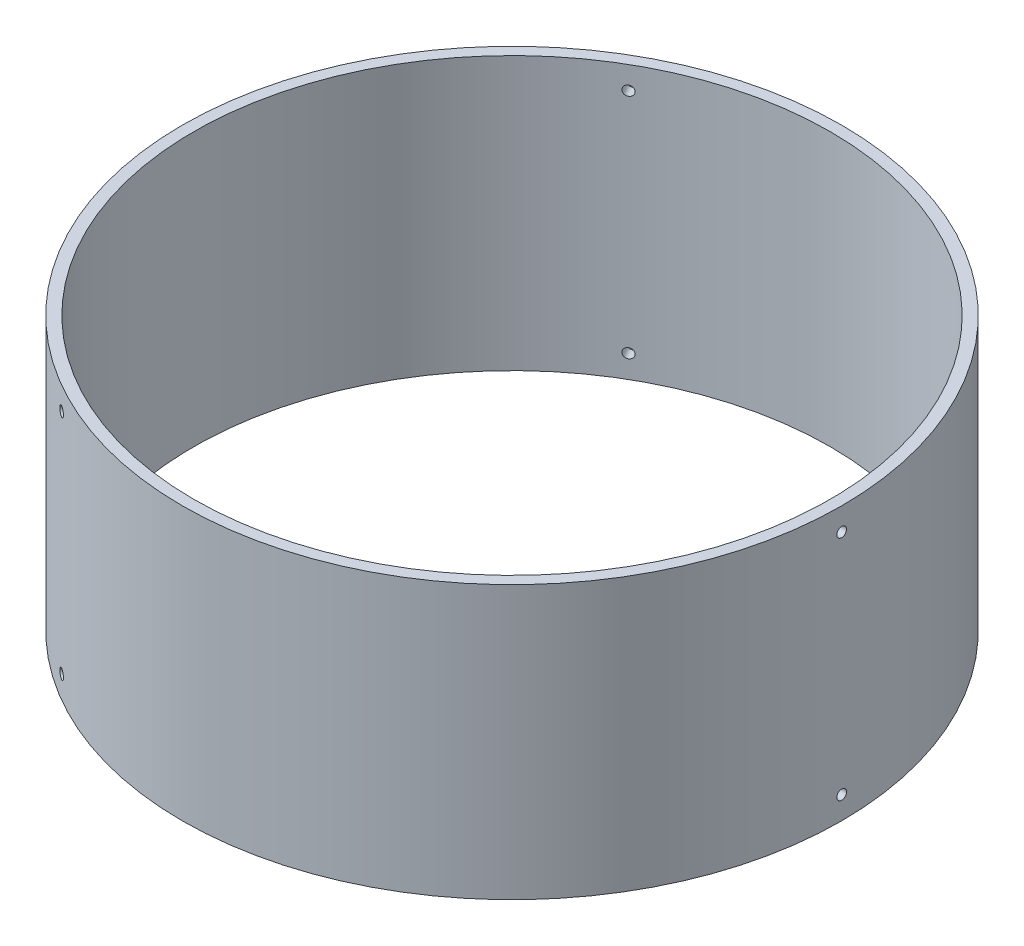
from build123d import *

# Parameters (mm, degrees)
SKETCH1_R           = 92.075
SKETCH1_R_2         = 88.9
BOSS_EXTRUDE1_DEPTH = 38.1
SKETCH3_R           = 1.35255
CUT_EXTRUDE1_DEPTH  = 34.798
CIRPATTERN1_COUNT   = 3


with BuildPart() as part:
    # Sketch1 → Boss-Extrude1 (new, symmetric)
    with BuildSketch(Plane(origin=(0, 0, 0), x_dir=(1, 0, 0), z_dir=(0, 1, 0))):
        with Locations(Location((0, 0, 0), (0, 0, 90))):
            Circle(SKETCH1_R)
        with Locations(Location((0, 0, 0), (0, 0, 90))):
            Circle(SKETCH1_R_2, mode=Mode.SUBTRACT)
    extrude(amount=BOSS_EXTRUDE1_DEPTH, both=True)

    # Sketch3 → Cut-Extrude1 (cut)
    with BuildSketch(Plane(origin=(92.075, 0, 0), x_dir=(0, 0, -1), z_dir=(1, 0, 0))):
        with Locations((0, -31.75)):
            Circle(SKETCH3_R)
        with Locations((0, 31.75)):
            Circle(SKETCH3_R)
    cut_extrude1 = extrude(amount=-CUT_EXTRUDE1_DEPTH, mode=Mode.SUBTRACT)

    # CirPattern1: Cut-Extrude1 ×3 about axis
    cirpattern1_axis = Axis((0, 38.1, 0), (0, -1, 0))
    for i in range(1, CIRPATTERN1_COUNT):
        add(cut_extrude1.rotate(cirpattern1_axis, i * 360 / CIRPATTERN1_COUNT), mode=Mode.SUBTRACT)


solid = part.part
